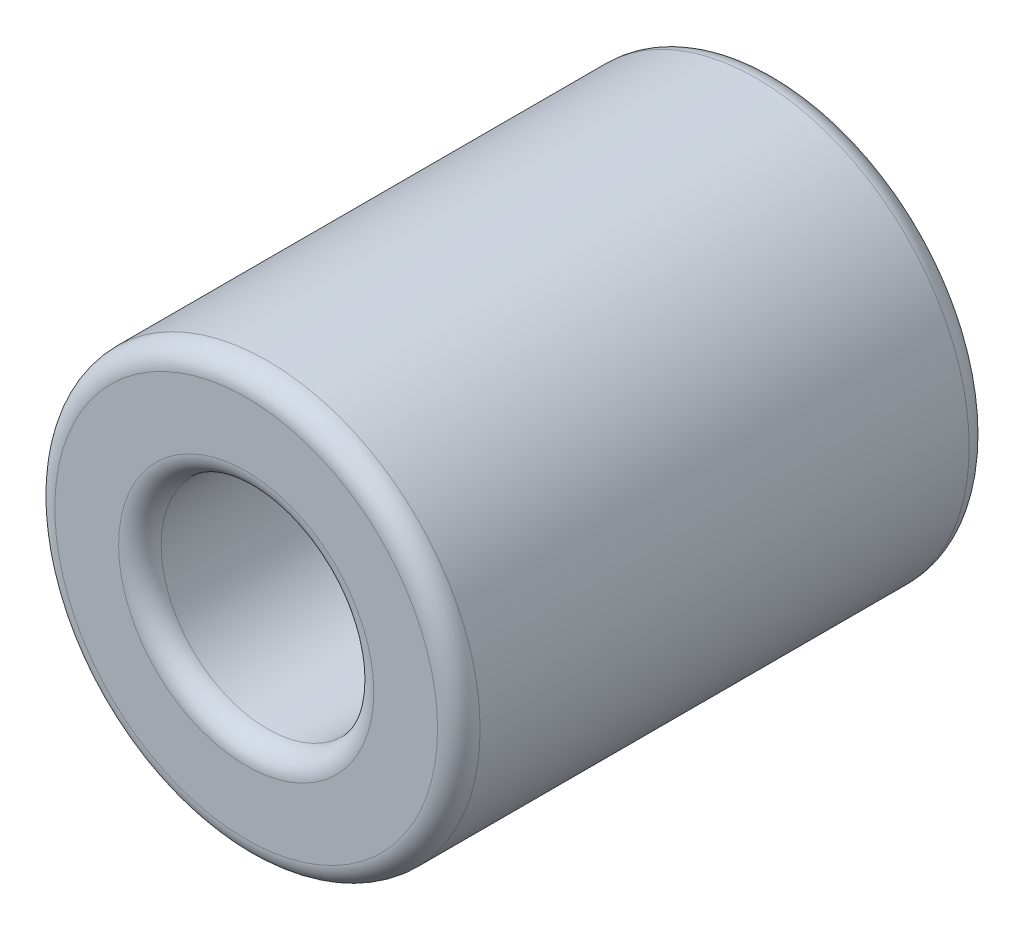
from build123d import *

# Parameters (mm, degrees)
SKETCH_1_R      = 10
SKETCH_1_R_2    = 5
EXTRUDE_1_DEPTH = 25
FILLET_1_R      = 1
SKETCH_2_R      = 6.96901779
EXTRUDE_2_DEPTH = 5


with BuildPart() as part:
    # 草图1 → 凸台-拉伸1 (new body)
    with BuildSketch(Plane.XY):
        Circle(SKETCH_1_R)
        Circle(SKETCH_1_R_2, mode=Mode.SUBTRACT)
    extrude(amount=EXTRUDE_1_DEPTH)

    # 圆角1
    fillet_1_edges = [part.edges().sort_by_distance(p)[0] for p in [
        (-10, 0, 0),
        (-10, 0, 25),
        (-5, 0, 0),
        (-5, 0, 25),
    ]]
    fillet(fillet_1_edges, radius=FILLET_1_R)

    # 草图2 → 凸台-拉伸2 (add)
    with BuildSketch(Plane(origin=(0, 0, 10), x_dir=(-1, 0, 0), z_dir=(0, 0, -1))):
        Circle(SKETCH_2_R)
    extrude(amount=-EXTRUDE_2_DEPTH)


solid = part.part
